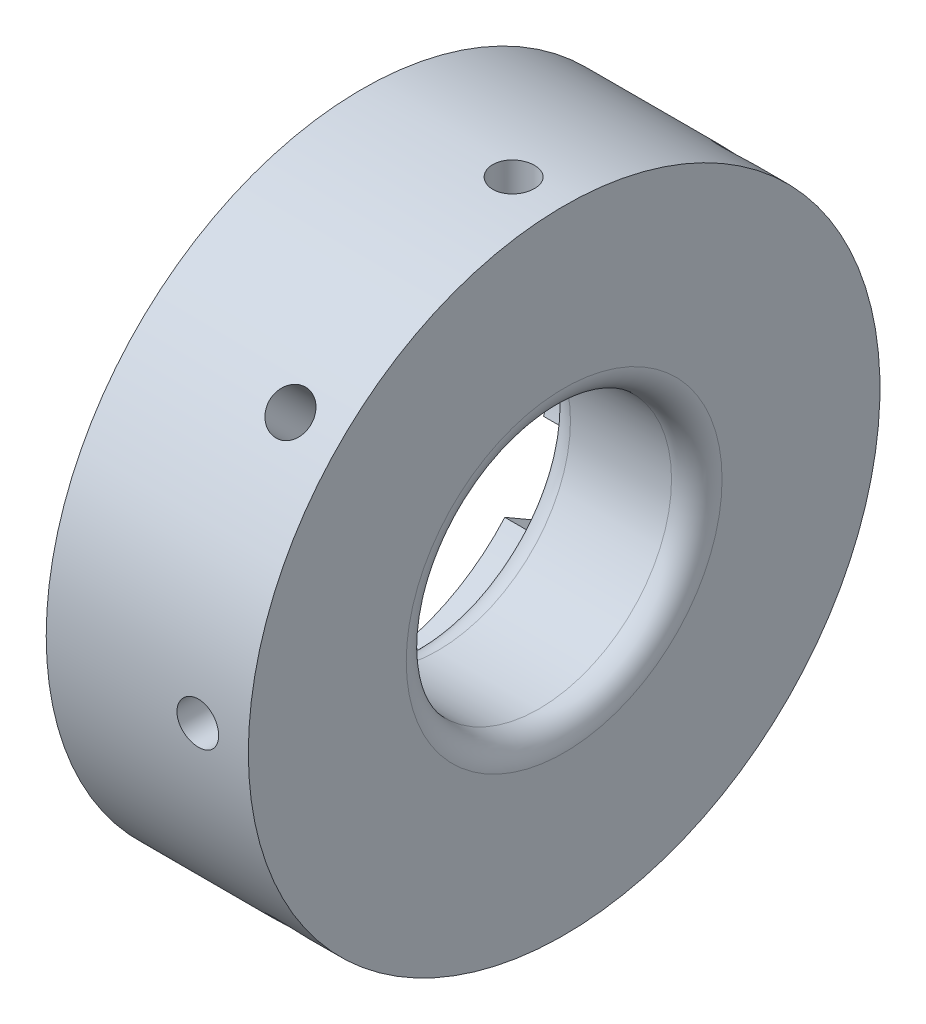
from build123d import *

# Parameters (mm, degrees)
ESQUISSE1_W                  = 16
ESQUISSE1_H                  = 14.5
ESQUISSE2_R                  = 4.1
ENL_V_MAT_EXTRU_1_DEPTH      = 4
CONG_2_R                     = 2
CONG_3_R                     = 2
ENL_V_START                  = 25
ESQUISSE3_R                  = 1.65
ENL_V_MAT_EXTRU_2_DEPTH      = 10
R_P_TITION_CIRCULAIRE1_COUNT = 8


with BuildPart() as part:
    # Esquisse1 → Révolution1 (revolve)
    with BuildSketch(Plane.XY, mode=Mode.PRIVATE) as r_volution1_sk:
        with Locations((8, 17.75)):
            Rectangle(ESQUISSE1_W, ESQUISSE1_H)
    revolve(r_volution1_sk.sketch.rotate(Axis((0, 0, 0), (1, 0, 0)), 90), axis=Axis((0, 0, 0), (1, 0, 0)))  # turned: the seam where the file's is

    # Esquisse2 → Enlèv. mat.-Extru.1 (cut)
    with BuildSketch(Plane.ZY):
        with BuildLine():
            Line((3.18, 14.761354951), (3.18, 18.999831578))
            ThreePointArc((3.18, 18.999831578), (0.08, 22.099831578), (-3.02, 18.999831578))
            Line((-3.02, 18.999831578), (-3.02, 14.794918046))
            ThreePointArc((-3.02, 14.794918046), (-7.479099439, 13.117662581), (-11.193708382, 10.13463826))
            Line((-11.193708382, 10.13463826), (-14.864336814, 12.253876573))
            ThreePointArc((-14.864336814, 12.253876573), (-19.099015566, 11.119197821), (-17.964336814, 6.88451907))
            Line((-17.964336814, 6.88451907), (-14.322774875, 4.782062304))
            ThreePointArc((-14.322774875, 4.782062304), (-15.099778753, 0.081741179), (-14.373708382, -4.626716692))
            Line((-14.373708382, -4.626716692), (-18.044336814, -6.745955005))
            ThreePointArc((-18.044336814, -6.745955005), (-19.179015566, -10.980633757), (-14.944336814, -12.115312509))
            Line((-14.944336814, -12.115312509), (-11.302774875, -10.012855743))
            ThreePointArc((-11.302774875, -10.012855743), (-7.620679314, -13.035921402), (-3.18, -14.761354951))
            Line((-3.18, -14.761354951), (-3.18, -18.999831578))
            ThreePointArc((-3.18, -18.999831578), (-0.08, -22.099831578), (3.02, -18.999831578))
            Line((3.02, -18.999831578), (3.02, -14.794918046))
            ThreePointArc((3.02, -14.794918046), (7.479099439, -13.117662581), (11.193708382, -10.13463826))
            Line((11.193708382, -10.13463826), (14.864336814, -12.253876573))
            ThreePointArc((14.864336814, -12.253876573), (19.099015566, -11.119197821), (17.964336814, -6.88451907))
            Line((17.964336814, -6.88451907), (14.322774875, -4.782062304))
            ThreePointArc((14.322774875, -4.782062304), (15.099778753, -0.081741179), (14.373708382, 4.626716692))
            Line((14.373708382, 4.626716692), (18.044336814, 6.745955005))
            ThreePointArc((18.044336814, 6.745955005), (19.179015566, 10.980633757), (14.944336814, 12.115312509))
            Line((14.944336814, 12.115312509), (11.302774875, 10.012855743))
            ThreePointArc((11.302774875, 10.012855743), (7.620679314, 13.035921402), (3.18, 14.761354951))
        make_face()
        Circle(ESQUISSE2_R, mode=Mode.SUBTRACT)
    extrude(amount=-ENL_V_MAT_EXTRU_1_DEPTH, mode=Mode.SUBTRACT)

    # Congé2
    cong_2_edges = [part.edges().sort_by_distance(p)[0] for p in [
        (4, 0, -10.5),
    ]]
    fillet(cong_2_edges, radius=CONG_2_R)

    # Congé3
    cong_3_edges = [part.edges().sort_by_distance(p)[0] for p in [
        (16, 0, -10.5),
    ]]
    fillet(cong_3_edges, radius=CONG_3_R)

    # Esquisse3 → Enlèv. mat.-Extru.2 (cut)
    with BuildSketch(Plane.XY.offset(ENL_V_START)):
        with Locations((12, 0)):
            Circle(ESQUISSE3_R)
    enl_v_mat_extru_2 = extrude(amount=-ENL_V_MAT_EXTRU_2_DEPTH, mode=Mode.SUBTRACT)

    # Répétition circulaire1: Enlèv. mat.-Extru.2 ×8 about axis
    r_p_tition_circulaire1_axis = Axis((0, 0, 0), (1, 0, 0))
    for i in range(1, R_P_TITION_CIRCULAIRE1_COUNT):
        add(enl_v_mat_extru_2.rotate(r_p_tition_circulaire1_axis, i * 360 / R_P_TITION_CIRCULAIRE1_COUNT), mode=Mode.SUBTRACT)


solid = part.part
